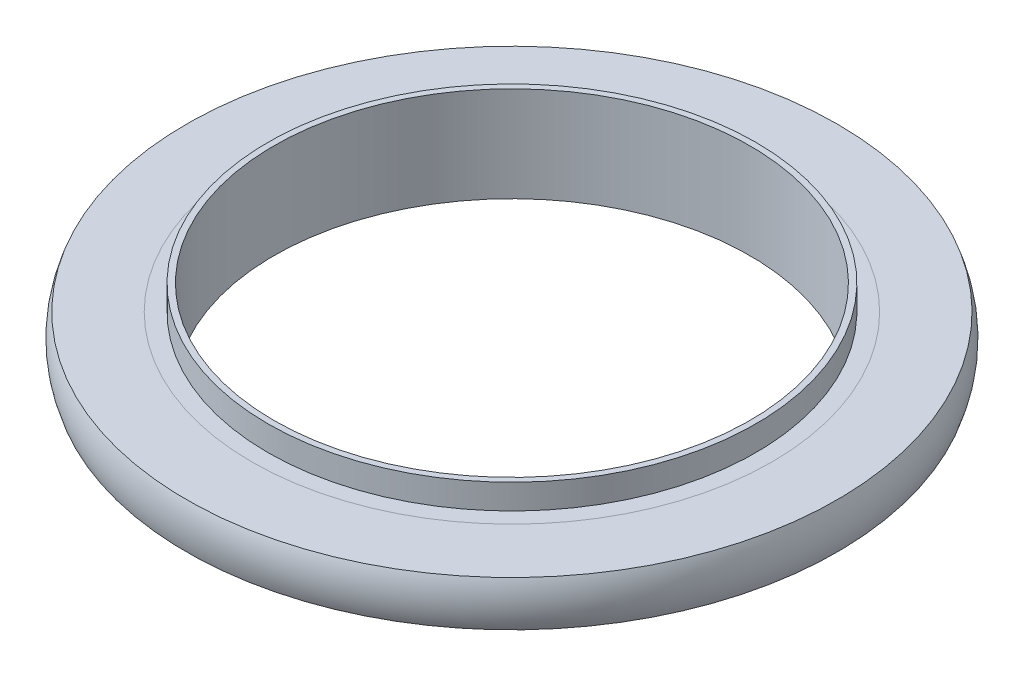
from build123d import *


with BuildPart() as part:
    # Sketch1 → Revolve1 (revolve)
    with BuildSketch(Plane.XY):
        with BuildLine():
            Line((20, 4), (20, -4))
            Line((20, -4), (20.5, -4))
            Line((20.5, -4), (20.5, -1.905))
            Line((20.5, -1.905), (21.854196223, -1.905))
            ThreePointArc((21.854196223, -1.905), (21.5, 0), (21.854196223, 1.905))
            Line((21.854196223, 1.905), (20.5, 1.905))
            Line((20.5, 1.905), (20.5, 4))
            Line((20.5, 4), (20, 4))
        make_face()
    revolve(axis=Axis((0, 4, 0), (0, -1, 0)))


with BuildPart() as body_2:
    # Sketch2 → Revolve2 (revolve)
    with BuildSketch(Plane.XY):
        with BuildLine():
            Line((21.854196223, 1.905), (27.345803777, 1.905))
            ThreePointArc((27.345803777, 1.905), (27.7, 0), (27.345803777, -1.905))
            Line((27.345803777, -1.905), (21.854196223, -1.905))
            ThreePointArc((21.854196223, -1.905), (21.5, 0), (21.854196223, 1.905))
        make_face()
    revolve(axis=Axis((0, -4, 0), (0, 1, 0)))


solid = Compound([part.part, body_2.part])
